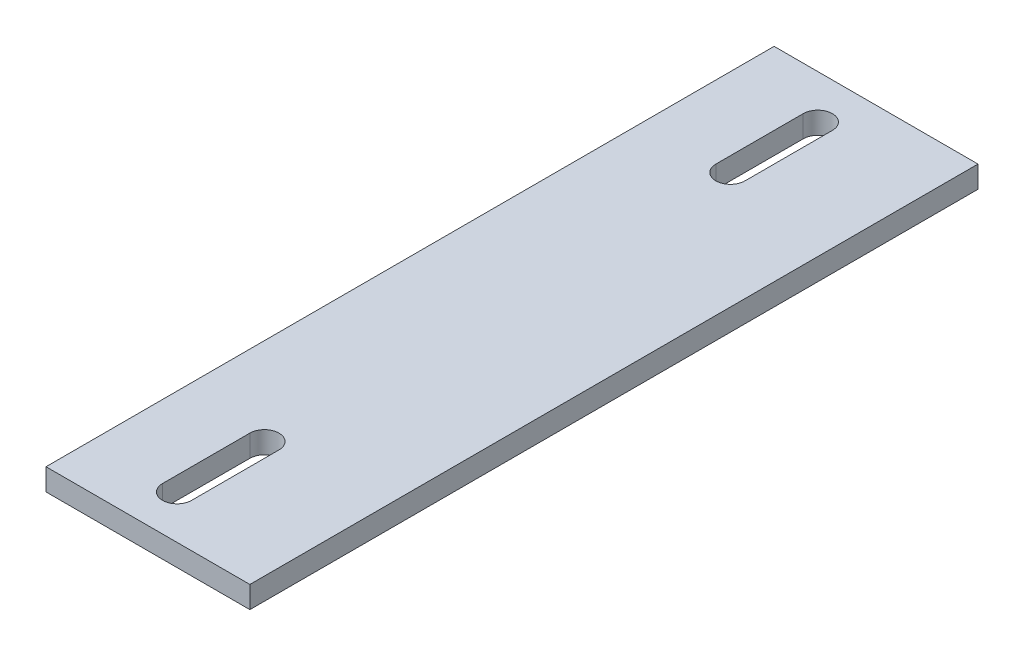
from build123d import *

# Parameters (mm, degrees)
SKETCH1_W           = 44.45
SKETCH1_H           = 158.75
BOSS_EXTRUDE1_DEPTH = 4.7625
CUT_EXTRUDE1_DEPTH  = 5.7625


with BuildPart() as part:
    # Sketch1 → Boss-Extrude1 (new body)
    with BuildSketch(Plane(origin=(0, 0, 0), x_dir=(1, 0, 0), z_dir=(0, 1, 0))):
        Rectangle(SKETCH1_W, SKETCH1_H)
    extrude(amount=BOSS_EXTRUDE1_DEPTH)

    # Sketch2 → Cut-Extrude1 (cut, through all)
    with BuildSketch(Plane(origin=(0, 4.7625, 0), x_dir=(1, 0, 0), z_dir=(0, 1, 0))):
        with BuildLine():
            Line((0, 50.8), (0, 69.85))
            ThreePointArc((0, 69.85), (-3.175, 73.025), (-6.35, 69.85))
            Line((-6.35, 69.85), (-6.35, 50.8))
            ThreePointArc((-6.35, 50.8), (-3.175, 47.625), (0, 50.8))
        make_face()
        with BuildLine():
            Line((-6.35, -50.8), (-6.35, -69.85))
            ThreePointArc((-6.35, -69.85), (-3.175, -73.025), (0, -69.85))
            Line((0, -69.85), (0, -50.8))
            ThreePointArc((0, -50.8), (-3.175, -47.625), (-6.35, -50.8))
        make_face()
    extrude(amount=-CUT_EXTRUDE1_DEPTH, mode=Mode.SUBTRACT)


solid = part.part
